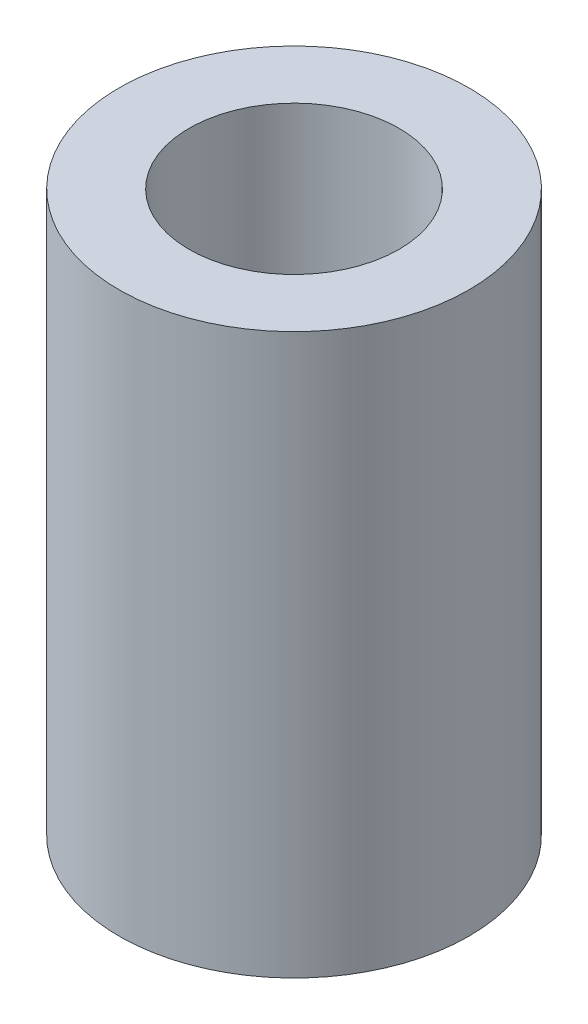
from build123d import *

# Parameters (mm, degrees)
SKETCH1_R           = 7.5
SKETCH1_R_2         = 4.5
EXTRUDE_THIN1_DEPTH = 24


with BuildPart() as part:
    # Sketch1 → Extrude-Thin1 (new body)
    with BuildSketch(Plane(origin=(0, 0, 0), x_dir=(1, 0, 0), z_dir=(0, 1, 0))):
        Circle(SKETCH1_R)
        Circle(SKETCH1_R_2, mode=Mode.SUBTRACT)
    extrude(amount=EXTRUDE_THIN1_DEPTH)


solid = part.part
